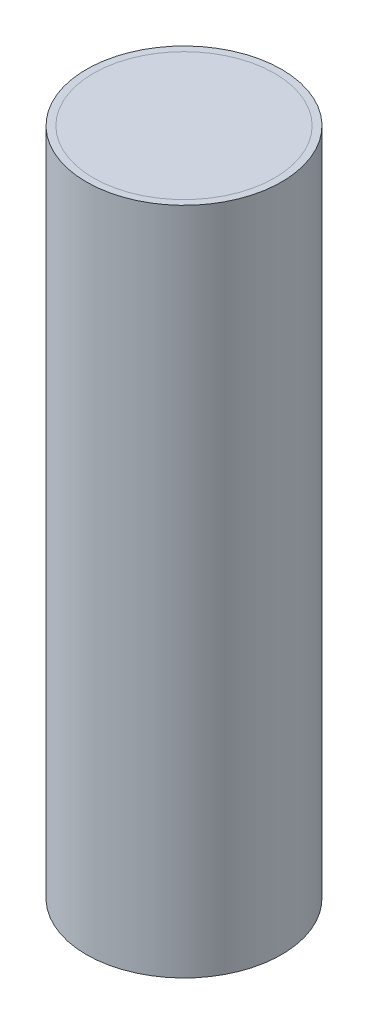
from build123d import *

# Parameters (mm, degrees)
SKETCH1_R           = 44.45
SKETCH1_R_2         = 41.275
BOSS_EXTRUDE1_DEPTH = 304.8
SKETCH1_2_R         = 41.275
BOSS_EXTRUDE2_DEPTH = 304.8


with BuildPart() as part:
    # Sketch1 → Boss-Extrude1 (new body)
    with BuildSketch(Plane(origin=(0, 0, 0), x_dir=(1, 0, 0), z_dir=(0, 1, 0))):
        Circle(SKETCH1_R)
        Circle(SKETCH1_R_2, mode=Mode.SUBTRACT)
    extrude(amount=BOSS_EXTRUDE1_DEPTH)


with BuildPart() as body_2:
    # Sketch1_2 → Boss-Extrude2 (new body)
    with BuildSketch(Plane(origin=(0, 0, 0), x_dir=(1, 0, 0), z_dir=(0, 1, 0))):
        Circle(SKETCH1_2_R)
    extrude(amount=BOSS_EXTRUDE2_DEPTH)


solid = Compound([part.part, body_2.part])
